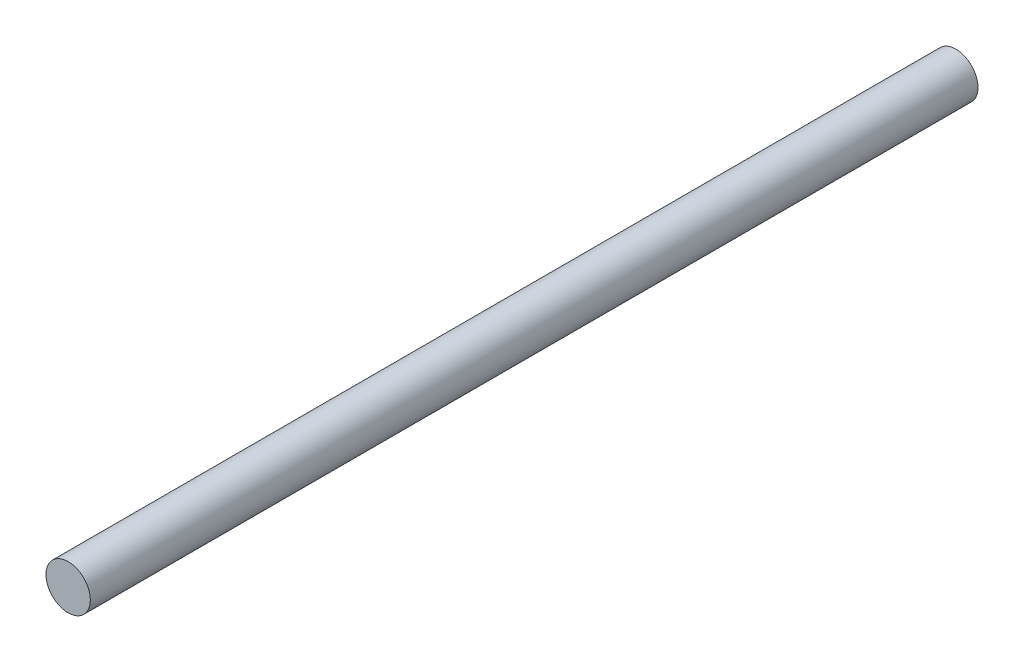
from build123d import *

# Parameters (mm, degrees)
ESQUISSE1_R        = 1
BOSS_EXTRU_1_DEPTH = 40


with BuildPart() as part:
    # Esquisse1 → Boss.-Extru.1 (new body)
    with BuildSketch(Plane.XY):
        Circle(ESQUISSE1_R)
    extrude(amount=-BOSS_EXTRU_1_DEPTH)


solid = part.part
